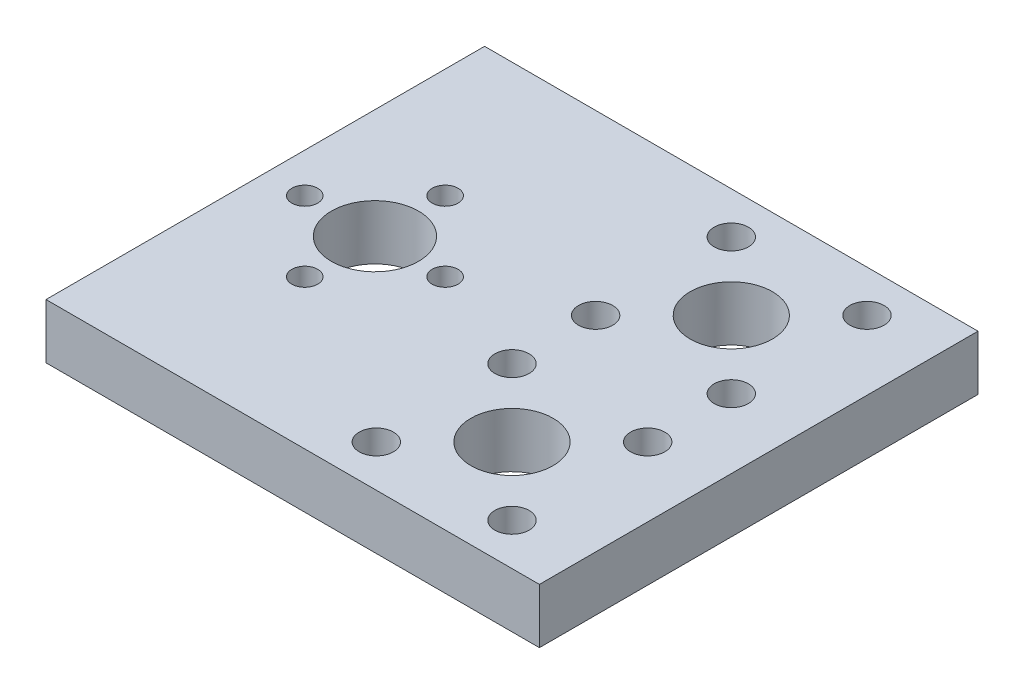
from build123d import *

# Parameters (mm, degrees)
SKETCH3_W           = 57.15
SKETCH3_H           = 6.35
BOSS_EXTRUDE2_DEPTH = 50.8
SKETCH4_R           = 5.05
SKETCH4_R_2         = 4.7625
SKETCH4_R_3         = 1.5
SKETCH4_R_4         = 1.984375
CUT_EXTRUDE1_DEPTH  = 6.35


with BuildPart() as part:
    # Sketch3 → Boss-Extrude2 (new body)
    with BuildSketch(Plane.XY):
        with Locations((-92.644673345, -3.175)):
            Rectangle(SKETCH3_W, SKETCH3_H)
    extrude(amount=BOSS_EXTRUDE2_DEPTH)

    # Sketch4 → Cut-Extrude1 (cut)
    with BuildSketch(Plane(origin=(0, 0, 0), x_dir=(1, 0, 0), z_dir=(0, 1, 0))):
        with Locations((-108.519673345, -25.4)):
            Circle(SKETCH4_R)
        with Locations((-79.944673345, -38.1)):
            Circle(SKETCH4_R_2)
        with Locations((-108.519673345, -17.27)):
            Circle(SKETCH4_R_3)
        with Locations((-87.802397451, -30.242275894)):
            Circle(SKETCH4_R_4)
        with Locations((-72.086949239, -30.242275894)):
            Circle(SKETCH4_R_4)
        with Locations((-72.086949239, -45.957724106)):
            Circle(SKETCH4_R_4)
        with Locations((-87.802397451, -45.957724106)):
            Circle(SKETCH4_R_4)
        with Locations((-116.649673345, -25.4)):
            Circle(SKETCH4_R_3)
        with Locations((-100.389673345, -25.4)):
            Circle(SKETCH4_R_3)
        with Locations((-108.519673345, -33.53)):
            Circle(SKETCH4_R_3)
        with Locations((-87.802397451, -4.842275894)):
            Circle(SKETCH4_R_4)
        with Locations((-72.086949239, -4.842275894)):
            Circle(SKETCH4_R_4)
        with Locations((-72.086949239, -20.557724106)):
            Circle(SKETCH4_R_4)
        with Locations((-87.802397451, -20.557724106)):
            Circle(SKETCH4_R_4)
        with Locations((-79.944673345, -12.7)):
            Circle(SKETCH4_R_2)
    extrude(amount=-CUT_EXTRUDE1_DEPTH, mode=Mode.SUBTRACT)


solid = part.part
